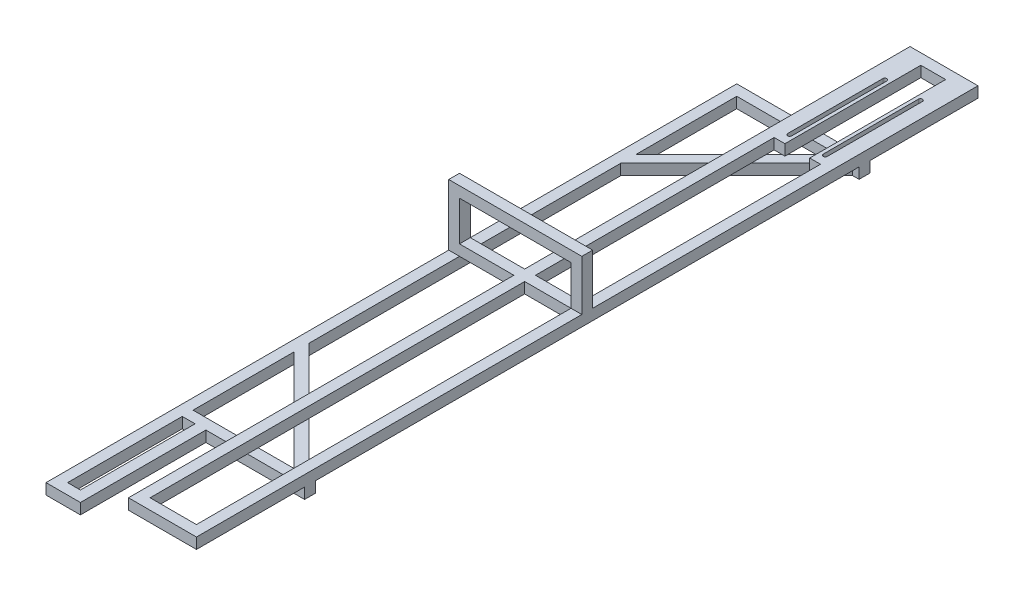
from build123d import *

# Parameters (mm, degrees)
SKETCH1_W           = 100
SKETCH1_H           = 1150
SKETCH1_W_2         = 68.25
SKETCH1_H_2         = 1118.25
BOSS_EXTRUDE1_DEPTH = 15.875
BOSS_EXTRUDE2_START = -15.875
BOSS_EXTRUDE2_DEPTH = 15.875
SKETCH5_W           = 195.875
SKETCH5_H           = 90
SKETCH5_W_2         = 164.125
SKETCH5_H_2         = 58.25
BOSS_EXTRUDE3_DEPTH = 7.9375
SKETCH6_W           = 15.875
SKETCH6_H           = 200
BOSS_EXTRUDE4_DEPTH = 15.875
CUT_EXTRUDE1_DEPTH  = 15.875
SKETCH8_W           = 50.625
SKETCH8_H           = 200.5
SKETCH8_W_2         = 18.875
SKETCH8_H_2         = 168.75
BOSS_EXTRUDE5_DEPTH = 15.875
BOSS_EXTRUDE6_DEPTH = 15.875


with BuildPart() as part:
    # Sketch1 → Boss-Extrude1 (new body)
    with BuildSketch(Plane(origin=(0, 0, 0), x_dir=(1, 0, 0), z_dir=(0, 1, 0))):
        Rectangle(SKETCH1_W, SKETCH1_H)
        Rectangle(SKETCH1_W_2, SKETCH1_H_2, mode=Mode.SUBTRACT)
    extrude(amount=BOSS_EXTRUDE1_DEPTH)

    # Sketch3 → Boss-Extrude2 (add)
    with BuildSketch(Plane(origin=(0, 15.875, 0), x_dir=(1, 0, 0), z_dir=(0, 1, 0)).offset(BOSS_EXTRUDE2_START)):
        Polygon((34.125, 400), (-130, 400), (-130, 220.59390888), (-130, -400), (34.125, -400), (50, -400), (50, -415.875), (-145.875, -415.875), (-145.875, 217.756753438), (-145.875, 415.875), (50, 415.875), (50, 400), align=None)
    extrude(amount=-BOSS_EXTRUDE2_DEPTH)

    # Sketch5 → Boss-Extrude3 (add, symmetric)
    with BuildSketch(Plane.XY):
        with Locations((-47.9375, 45)):
            Rectangle(SKETCH5_W, SKETCH5_H)
        with Locations((-47.9375, 45)):
            Rectangle(SKETCH5_W_2, SKETCH5_H_2, mode=Mode.SUBTRACT)
    extrude(amount=BOSS_EXTRUDE3_DEPTH, both=True)

    # Sketch6 → Boss-Extrude4 (add)
    with BuildSketch(Plane.XZ):
        with Locations((-26.1875, -459.125)):
            Rectangle(SKETCH6_W, SKETCH6_H)
        with Locations((26.1875, -459.125)):
            Rectangle(SKETCH6_W, SKETCH6_H)
    extrude(amount=-BOSS_EXTRUDE4_DEPTH)

    # Sketch7 → Cut-Extrude1 (cut)
    with BuildSketch(Plane.XZ):
        with BuildLine():
            Line((-23.1875, -374.125), (-23.1875, -514.125))
            ThreePointArc((-23.1875, -514.125), (-26.1875, -517.125), (-29.1875, -514.125))
            Line((-29.1875, -514.125), (-29.1875, -374.125))
            ThreePointArc((-29.1875, -374.125), (-26.1875, -371.125), (-23.1875, -374.125))
        make_face()
        with BuildLine():
            Line((29.1875, -374.125), (29.1875, -514.125))
            ThreePointArc((29.1875, -514.125), (26.1875, -517.125), (23.1875, -514.125))
            Line((23.1875, -514.125), (23.1875, -374.125))
            ThreePointArc((23.1875, -374.125), (26.1875, -371.125), (29.1875, -374.125))
        make_face()
    extrude(amount=-CUT_EXTRUDE1_DEPTH, mode=Mode.SUBTRACT)

    # Sketch8 → Boss-Extrude5 (add)
    with BuildSketch(Plane(origin=(0, 0, 0), x_dir=(1, 0, 0), z_dir=(0, 1, 0))):
        with Locations((-120.5625, -500.25)):
            Rectangle(SKETCH8_W, SKETCH8_H)
        with Locations((-120.5625, -500.25)):
            Rectangle(SKETCH8_W_2, SKETCH8_H_2, mode=Mode.SUBTRACT)
    extrude(amount=-BOSS_EXTRUDE5_DEPTH)

    # Sketch9 → Boss-Extrude6 (add)
    with BuildSketch(Plane(origin=(0, 0, 0), x_dir=(1, 0, 0), z_dir=(0, 1, 0))):
        Polygon((45.350320151, -404.649679849), (34.125, -415.875), (-145.875, -235.875), (-134.649679849, -224.649679849), align=None)
    boss_extrude6 = extrude(amount=-BOSS_EXTRUDE6_DEPTH)

    # Mirror1: Boss-Extrude6 across plane
    add(boss_extrude6.mirror(Plane.XY))


solid = part.part
